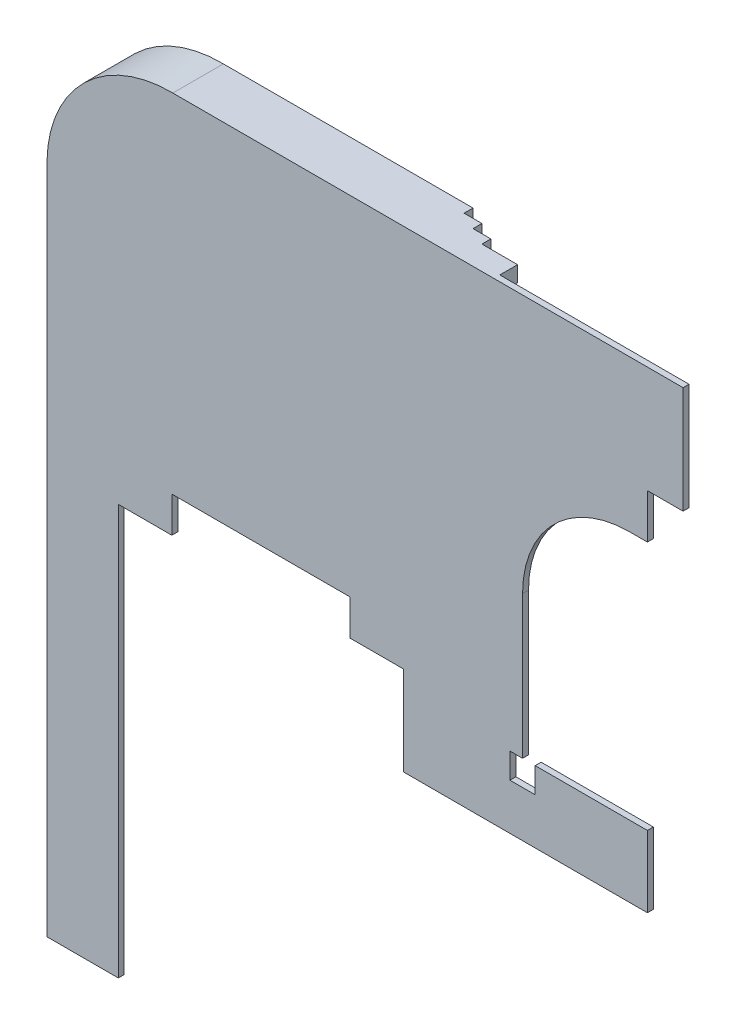
from build123d import *

# Parameters (mm, degrees)
BOSS_EXTRUDE1_DEPTH = 101.6
BOSS_EXTRUDE2_DEPTH = 558.8
BOSS_EXTRUDE3_DEPTH = 863.6
CUT_EXTRUDE1_DEPTH  = 24425.756146057
CUT_EXTRUDE2_DEPTH  = 35918.479626981
CUT_EXTRUDE3_DEPTH  = 39956.790586087
SKETCH6_W           = 431.8
SKETCH6_H           = 431.8
CUT_EXTRUDE4_DEPTH  = 39956.790586087
SKETCH7_W           = 1219.2
SKETCH7_H           = 7010.4
CUT_EXTRUDE5_DEPTH  = 0.254


with BuildPart() as part:
    # Sketch1 → Boss-Extrude1 (new body)
    with BuildSketch(Plane.XY):
        with BuildLine():
            Line((-20469.8646362, 20741.718375844), (-19250.6646362, 20741.718375844))
            Line((-19250.6646362, 20741.718375844), (-19250.6646362, 27752.118375844))
            Line((-19250.6646362, 27752.118375844), (-18336.2646362, 27752.118375844))
            Line((-18336.2646362, 27752.118375844), (-18336.2646362, 28361.718375844))
            Line((-18336.2646362, 28361.718375844), (-15288.2646362, 28361.718375844))
            Line((-15288.2646362, 28361.718375844), (-15288.2646362, 27752.118375844))
            Line((-15288.2646362, 27752.118375844), (-14373.8646362, 27752.118375844))
            Line((-14373.8646362, 27752.118375844), (-14373.8646362, 26228.118375844))
            Line((-14373.8646362, 26228.118375844), (-10208.2646362, 26228.118375844))
            Line((-10208.2646362, 26228.118375844), (-10208.2646362, 32476.518375844))
            Line((-10208.2646362, 32476.518375844), (-9598.6646362, 32476.518375844))
            Line((-9598.6646362, 32476.518375844), (-9598.6646362, 34305.318375844))
            Line((-9598.6646362, 34305.318375844), (-12832.803535515, 34305.318375844))
            Line((-12832.803535515, 34305.318375844), (-12832.803535515, 34038.618375844))
            Line((-12832.803535515, 34038.618375844), (-17739.369265567, 34038.618375844))
            Line((-17739.369265567, 34038.618375844), (-17739.369265567, 33683.018375844))
            Line((-17739.369265567, 33683.018375844), (-18348.969265567, 33683.018375844))
            ThreePointArc((-18348.969265567, 33683.018375844), (-19408.851608728, 33243.876434785), (-19847.569145444, 32183.818347357))
            Line((-19847.569145444, 32183.818347357), (-19847.325066059, 31574.218396221))
            Line((-19847.325066059, 31574.218396221), (-20202.925037555, 31574.07601658))
            Line((-20202.925037555, 31574.07601658), (-20202.925037555, 29166.512154459))
            Line((-20202.925037555, 29166.512154459), (-20469.8646362, 29166.512154459))
            Line((-20469.8646362, 29166.512154459), (-20469.8646362, 20741.718375844))
        make_face()
    extrude(amount=-BOSS_EXTRUDE1_DEPTH)

    # Sketch1_15 → Boss-Extrude2 (add)
    with BuildSketch(Plane.XY):
        with BuildLine():
            Line((-20202.925037555, 32214.512154459), (-20202.925037555, 31574.07601658))
            Line((-20202.925037555, 31574.07601658), (-19847.325066059, 31574.218396221))
            Line((-19847.325066059, 31574.218396221), (-19847.569145444, 32183.818347357))
            ThreePointArc((-19847.569145444, 32183.818347357), (-19408.851608728, 33243.876434785), (-18348.969265567, 33683.018375844))
            Line((-18348.969265567, 33683.018375844), (-17739.369265567, 33683.018375844))
            Line((-17739.369265567, 33683.018375844), (-17739.369265567, 34038.618375844))
            Line((-17739.369265567, 34038.618375844), (-18348.969265567, 34038.618375844))
            ThreePointArc((-18348.969265567, 34038.618375844), (-19649.403376872, 33506.132702828), (-20202.925037555, 32214.512154459))
        make_face()
    extrude(amount=-BOSS_EXTRUDE2_DEPTH)

    # Sketch1_17 → Boss-Extrude3 (add)
    with BuildSketch(Plane.XY):
        with BuildLine():
            Line((-20469.864636201, 32214.512154459), (-20469.8646362, 29166.512154459))
            Line((-20469.8646362, 29166.512154459), (-20202.925037555, 29166.512154459))
            Line((-20202.925037555, 29166.512154459), (-20202.925037555, 31574.07601658))
            Line((-20202.925037555, 31574.07601658), (-20202.925037555, 32214.512154459))
            ThreePointArc((-20202.925037555, 32214.512154459), (-19649.403376872, 33506.132702828), (-18348.969265567, 34038.618375844))
            Line((-18348.969265567, 34038.618375844), (-17739.369265567, 34038.618375844))
            Line((-17739.369265567, 34038.618375844), (-12832.803535515, 34038.618375844))
            Line((-12832.803535515, 34038.618375844), (-12832.803535515, 34305.318375844))
            Line((-12832.803535515, 34305.318375844), (-18319.203535515, 34305.318375844))
            ThreePointArc((-18319.203535515, 34305.318375844), (-19827.50687323, 33705.283048131), (-20469.864636201, 32214.512154459))
        make_face()
    extrude(amount=-BOSS_EXTRUDE3_DEPTH)

    # Sketch3 → Cut-Extrude1 (cut, through all)
    with BuildSketch(Plane.XZ.offset(-34038.618375844)):
        Polygon((-13747.203535515, -558.8), (-13747.203535515, -711.2), (-14052.003535515, -711.2), (-14052.003535515, -863.6), (-12832.803535515, -863.6), (-12832.803535515, -406.4), (-13442.403535515, -406.4), (-13442.403535515, -558.8), align=None)
    extrude(amount=-CUT_EXTRUDE1_DEPTH, mode=Mode.SUBTRACT)

    # Sketch4 → Cut-Extrude2 (cut, through all)
    with BuildSketch(Plane(origin=(-20202.925037555, 0, 0), x_dir=(0, 0, -1), z_dir=(1, 0, 0))):
        Polygon((863.6, 29166.51215446), (406.4, 29166.51215446), (406.4, 29776.11215446), (558.8, 29776.11215446), (558.8, 30080.91215446), (711.2, 30080.91215446), (711.2, 30385.71215446), (863.6, 30385.71215446), (863.6, 30080.91215446), align=None)
    extrude(amount=-CUT_EXTRUDE2_DEPTH, mode=Mode.SUBTRACT)

    # Sketch5 → Cut-Extrude3 (cut, through all)
    with BuildSketch(Plane(origin=(0, 0, -101.6), x_dir=(-1, 0, 0), z_dir=(0, 0, -1))):
        with BuildLine():
            Line((10208.2646362, 27447.318375844), (12341.8646362, 27447.318375844))
            Line((12341.8646362, 27447.318375844), (12341.8646362, 29885.718375844))
            ThreePointArc((12341.8646362, 29885.718375844), (11806.221517634, 31178.875257278), (10513.0646362, 31714.518375844))
            Line((10513.0646362, 31714.518375844), (10208.2646362, 31714.518375844))
            Line((10208.2646362, 31714.518375844), (10208.2646362, 27447.318375844))
        make_face()
    extrude(amount=-CUT_EXTRUDE3_DEPTH, mode=Mode.SUBTRACT)

    # Sketch6 → Cut-Extrude4 (cut, through all)
    with BuildSketch(Plane(origin=(0, 0, -101.6), x_dir=(-1, 0, 0), z_dir=(0, 0, -1))):
        with Locations((12341.8646362, 27231.418375844)):
            Rectangle(SKETCH6_W, SKETCH6_H)
    extrude(amount=-CUT_EXTRUDE4_DEPTH, mode=Mode.SUBTRACT)

    # Sketch7 → Cut-Extrude5 (cut)
    with BuildSketch(Plane(origin=(0, 0, -101.6), x_dir=(-1, 0, 0), z_dir=(0, 0, -1))):
        with Locations((19860.2646362, 24246.918375844)):
            Rectangle(SKETCH7_W, SKETCH7_H)
    extrude(amount=-CUT_EXTRUDE5_DEPTH, mode=Mode.SUBTRACT)


solid = part.part
